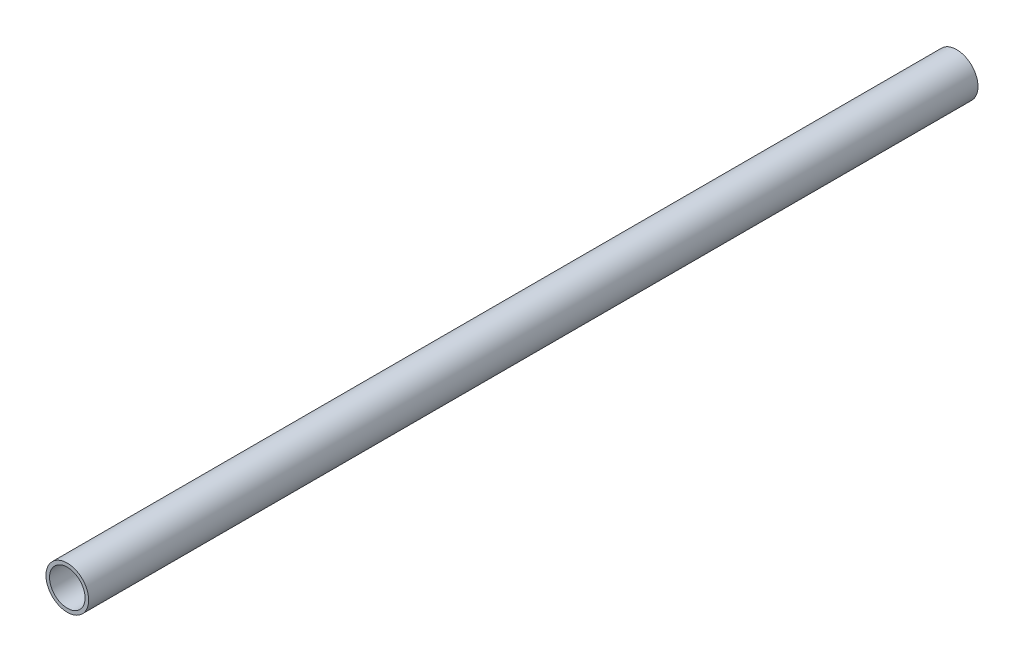
from build123d import *

# Parameters (mm, degrees)
SKETCH_1_R          = 6
EXTRUDE_1_DEPTH     = 250
SKETCH_2_R          = 5
CUT_EXTRUDE_1_DEPTH = 300


with BuildPart() as part:
    # 草图1 → 凸台-拉伸1 (new body)
    with BuildSketch(Plane.XY):
        Circle(SKETCH_1_R)
    extrude(amount=EXTRUDE_1_DEPTH)

    # 草图2 → 切除-拉伸1 (cut)
    with BuildSketch(Plane(origin=(0, 0, 0), x_dir=(-1, 0, 0), z_dir=(0, 0, -1))):
        Circle(SKETCH_2_R)
    extrude(amount=-CUT_EXTRUDE_1_DEPTH, mode=Mode.SUBTRACT)


solid = part.part
